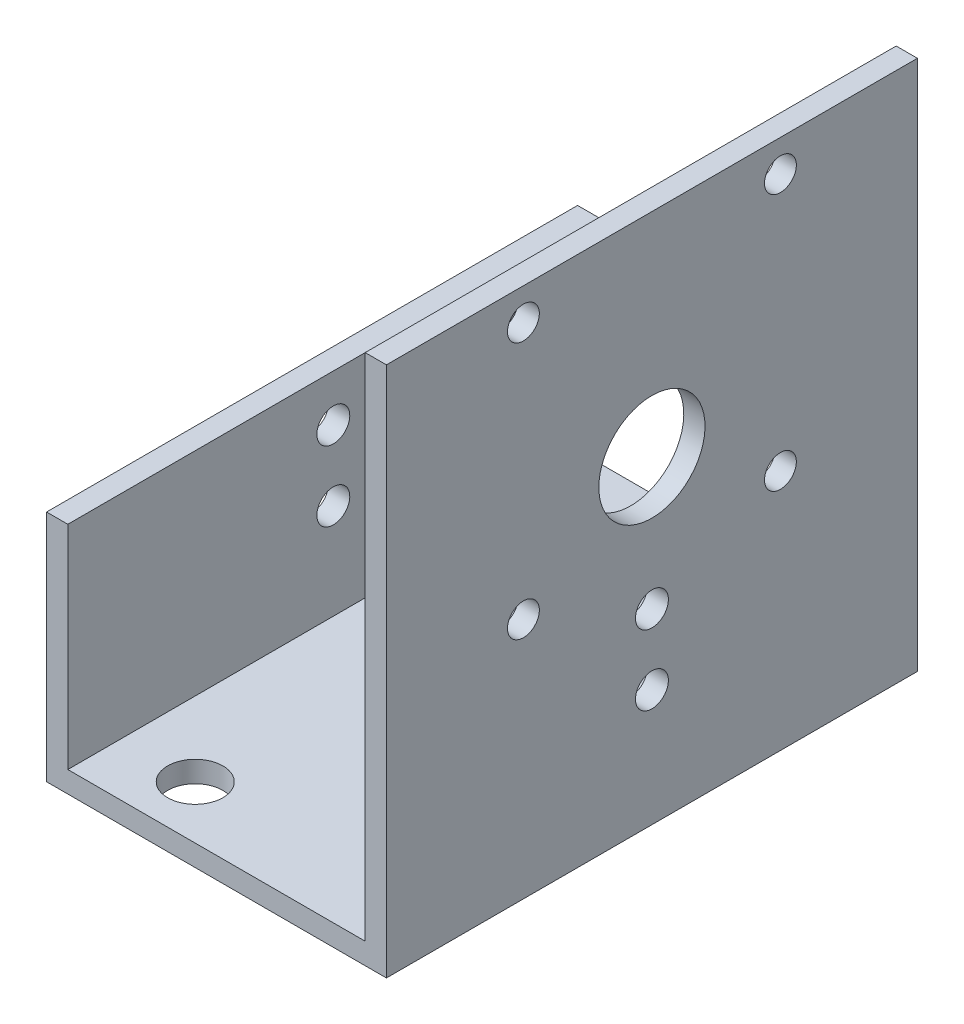
from build123d import *

# Parameters (mm, degrees)
EXTRUSION1_DEPTH        = 25
ESQUISSE2_R             = 1.5
ESQUISSE2_R_2           = 5
ENL_V_MAT_EXTRU_1_DEPTH = 10
ESQUISSE3_R             = 1.55
ENL_V_MAT_EXTRU_2_DEPTH = 33
ESQUISSE4_R             = 2.6
ENL_V_MAT_EXTRU_3_DEPTH = 10


with BuildPart() as part:
    # Esquisse1 → Extrusion1 (new body, symmetric)
    with BuildSketch(Plane.XY):
        Polygon((0, 0), (2, 0), (2, -50), (-28, -50), (-30, -50), (-30, -28), (-28, -28), (-28, -48), (0, -48), align=None)
    extrude(amount=EXTRUSION1_DEPTH, both=True)

    # Esquisse2 → Enlèv. mat.-Extru.1 (cut)
    with BuildSketch(Plane(origin=(2, 0, 0), x_dir=(0, 0, -1), z_dir=(1, 0, 0))):
        with Locations(Location((-12.1, -3, 0), (0, 0, 90))):  # turned: the seam where the file's is
            Circle(ESQUISSE2_R)
        with Locations(Location((-12.1, -27.2, 0), (0, 0, 90))):  # turned: the seam where the file's is
            Circle(ESQUISSE2_R)
        with Locations(Location((12.1, -27.2, 0), (0, 0, 90))):  # turned: the seam where the file's is
            Circle(ESQUISSE2_R)
        with Locations(Location((12.1, -3, 0), (0, 0, 90))):  # turned: the seam where the file's is
            Circle(ESQUISSE2_R)
        with Locations(Location((0, -20, 0), (0, 0, 90))):  # turned: the seam where the file's is
            Circle(ESQUISSE2_R_2)
    extrude(amount=-ENL_V_MAT_EXTRU_1_DEPTH, mode=Mode.SUBTRACT)

    # Esquisse3 → Enlèv. mat.-Extru.2 (cut, through all)
    with BuildSketch(Plane(origin=(2, 0, 0), x_dir=(0, 0, -1), z_dir=(1, 0, 0))):
        with Locations(Location((0, -32.4, 0), (0, 0, 90))):  # turned: the seam where the file's is
            Circle(ESQUISSE3_R)
        with Locations(Location((0, -39, 0), (0, 0, 90))):  # turned: the seam where the file's is
            Circle(ESQUISSE3_R)
    extrude(amount=-ENL_V_MAT_EXTRU_2_DEPTH, mode=Mode.SUBTRACT)

    # Esquisse4 → Enlèv. mat.-Extru.3 (cut)
    with BuildSketch(Plane.XZ.offset(50)):
        with Locations(Location((-21, 20, 0), (0, 0, 270))):  # turned: the seam where the file's is
            Circle(ESQUISSE4_R)
        with Locations(Location((-21, -20, 0), (0, 0, 270))):  # turned: the seam where the file's is
            Circle(ESQUISSE4_R)
    extrude(amount=-ENL_V_MAT_EXTRU_3_DEPTH, mode=Mode.SUBTRACT)


solid = part.part
